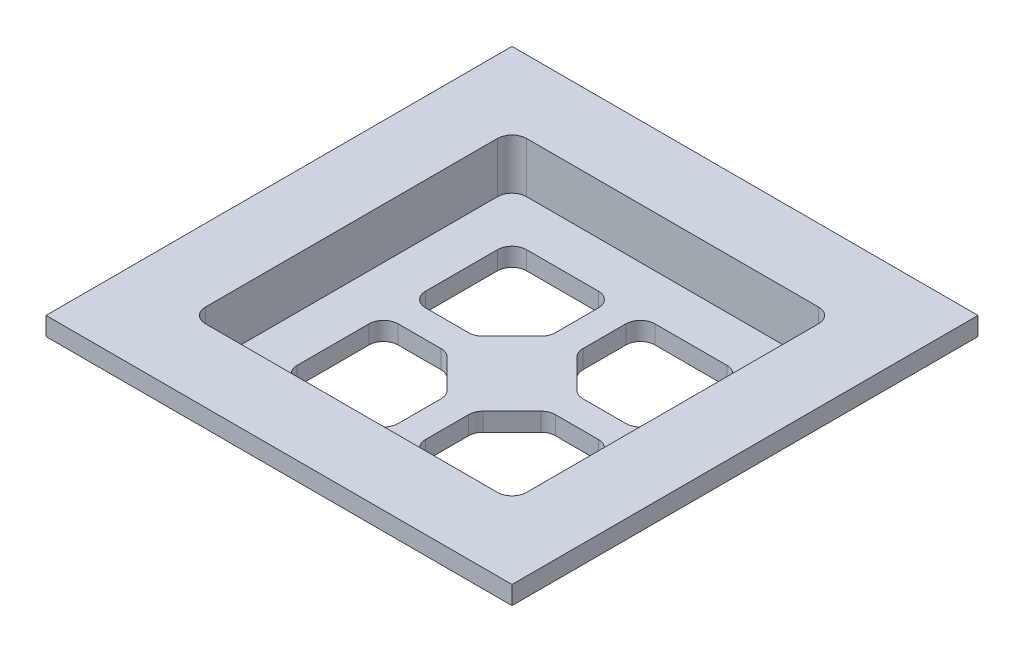
from build123d import *

# Parameters (mm, degrees)
SKETCH3_W           = 47.117
SKETCH3_H           = 47.117
BOSS_EXTRUDE1_DEPTH = 5.500799822
CUT_EXTRUDE2_REACH  = 7.501
SKETCH6_W           = 11
SKETCH6_H           = 11
SKETCH7_W           = 50.8
SKETCH7_H           = 50.8
SKETCH7_W_2         = 35
SKETCH7_H_2         = 35
BOSS_EXTRUDE2_DEPTH = 1.999999976
SKETCH12_W          = 35
SKETCH12_H          = 35
CUT_EXTRUDE3_DEPTH  = 3.499999912
BOSS_EXTRUDE4_DEPTH = 2.0008
FILLET3_R           = 1.5875
CUT_EXTRUDE5_DEPTH  = 5.5008


with BuildPart() as part:
    # Sketch3 → Boss-Extrude1 (new body)
    with BuildSketch(Plane(origin=(0, 0, 0), x_dir=(1, 0, 0), z_dir=(0, 1, 0))):
        with Locations((23.8125, 23.8125)):
            Rectangle(SKETCH3_W, SKETCH3_H)
    extrude(amount=BOSS_EXTRUDE1_DEPTH)

    # Sketch6 → Cut-Extrude2 (cut, up to next)
    with BuildSketch(Plane(origin=(0, 5.500799822, 0), x_dir=(1, 0, 0), z_dir=(0, 1, 0)), mode=Mode.PRIVATE) as cut_extrude2_sk1:
        with Locations((16.8125, 30.8125)):
            Rectangle(SKETCH6_W, SKETCH6_H)
    cut_extrude2_tool1 = extrude(cut_extrude2_sk1.sketch, amount=-CUT_EXTRUDE2_REACH, mode=Mode.PRIVATE) & part.part
    add(cut_extrude2_tool1.solids().sort_by_distance((16.8125, 5.5008, -30.8125))[0], mode=Mode.SUBTRACT)
    # Sketch6 → Cut-Extrude2 (cut, up to next)
    with BuildSketch(Plane(origin=(0, 5.500799822, 0), x_dir=(1, 0, 0), z_dir=(0, 1, 0)), mode=Mode.PRIVATE) as cut_extrude2_sk2:
        with Locations((30.8125, 30.8125)):
            Rectangle(SKETCH6_W, SKETCH6_H)
    cut_extrude2_tool2 = extrude(cut_extrude2_sk2.sketch, amount=-CUT_EXTRUDE2_REACH, mode=Mode.PRIVATE) & part.part
    add(cut_extrude2_tool2.solids().sort_by_distance((30.8125, 5.5008, -30.8125))[0], mode=Mode.SUBTRACT)
    # Sketch6 → Cut-Extrude2 (cut, up to next)
    with BuildSketch(Plane(origin=(0, 5.500799822, 0), x_dir=(1, 0, 0), z_dir=(0, 1, 0)), mode=Mode.PRIVATE) as cut_extrude2_sk3:
        with Locations((30.8125, 16.8125)):
            Rectangle(SKETCH6_W, SKETCH6_H)
    cut_extrude2_tool3 = extrude(cut_extrude2_sk3.sketch, amount=-CUT_EXTRUDE2_REACH, mode=Mode.PRIVATE) & part.part
    add(cut_extrude2_tool3.solids().sort_by_distance((30.8125, 5.5008, -16.8125))[0], mode=Mode.SUBTRACT)
    # Sketch6 → Cut-Extrude2 (cut, up to next)
    with BuildSketch(Plane(origin=(0, 5.500799822, 0), x_dir=(1, 0, 0), z_dir=(0, 1, 0)), mode=Mode.PRIVATE) as cut_extrude2_sk4:
        with Locations((16.8125, 16.8125)):
            Rectangle(SKETCH6_W, SKETCH6_H)
    cut_extrude2_tool4 = extrude(cut_extrude2_sk4.sketch, amount=-CUT_EXTRUDE2_REACH, mode=Mode.PRIVATE) & part.part
    add(cut_extrude2_tool4.solids().sort_by_distance((16.8125, 5.5008, -16.8125))[0], mode=Mode.SUBTRACT)

    # Sketch7 → Boss-Extrude2 (add)
    with BuildSketch(Plane(origin=(0, 5.500799822, 0), x_dir=(1, 0, 0), z_dir=(0, 1, 0))):
        with Locations((23.8125, 23.8125)):
            Rectangle(SKETCH7_W, SKETCH7_H)
        with Locations((23.8125, 23.8125)):
            Rectangle(SKETCH7_W_2, SKETCH7_H_2, mode=Mode.SUBTRACT)
    extrude(amount=BOSS_EXTRUDE2_DEPTH)

    # Sketch12 → Cut-Extrude3 (cut)
    with BuildSketch(Plane(origin=(0, 5.500799822, 0), x_dir=(1, 0, 0), z_dir=(0, 1, 0))):
        with Locations((23.8125, 23.8125)):
            Rectangle(SKETCH12_W, SKETCH12_H)
    extrude(amount=-CUT_EXTRUDE3_DEPTH, mode=Mode.SUBTRACT)

    # Sketch11 → Boss-Extrude4 (add)
    with BuildSketch(Plane(origin=(0, 2.00079991, 0), x_dir=(1, 0, 0), z_dir=(0, 1, 0))):
        Polygon((22.3125, 29.383567812), (25.3125, 29.383567812), (29.383567812, 25.3125), (29.383567812, 22.3125), (25.3125, 18.241432188), (22.3125, 18.241432188), (18.241432188, 22.3125), (18.241432188, 25.3125), align=None)
    extrude(amount=-BOSS_EXTRUDE4_DEPTH)

    # Fillet3
    fillet3_edges = [part.edges().sort_by_distance(p)[0] for p in [
        (29.383567812, 1.00039991, -22.3125),
        (25.3125, 1.00039991, -18.241432188),
        (22.3125, 1.00039991, -18.241432188),
        (18.241432188, 1.00039991, -22.3125),
        (18.241432188, 1.00039991, -25.3125),
        (22.3125, 1.00039991, -29.383567812),
        (25.3125, 1.00039991, -29.383567812),
        (29.383567812, 1.00039991, -25.3125),
        (36.3125, 1.000399955, -22.3125),
        (36.3125, 1.000399955, -11.3125),
        (25.3125, 1.000399955, -11.3125),
        (11.3125, 1.000399955, -36.3125),
        (22.3125, 1.000399955, -36.3125),
        (11.3125, 1.000399955, -25.3125),
        (22.3125, 1.000399955, -11.3125),
        (11.3125, 1.000399955, -11.3125),
        (11.3125, 1.000399955, -22.3125),
        (36.3125, 1.000399955, -25.3125),
        (25.3125, 1.000399955, -36.3125),
        (36.3125, 1.000399955, -36.3125),
        (6.3125, 4.750799854, -6.3125),
        (41.3125, 4.750799854, -6.3125),
        (41.3125, 4.750799854, -41.3125),
        (6.3125, 4.750799854, -41.3125),
        (0.254, 2.750399911, -47.371),
        (47.371, 2.750399911, -47.371),
        (47.371, 2.750399911, -0.254),
        (0.254, 2.750399911, -0.254),
    ]]
    fillet(fillet3_edges, radius=FILLET3_R)

    # Sketch13 → Cut-Extrude5 (cut)
    with BuildSketch(Plane.XZ):
        with BuildLine():
            Line((0.254, -1.8415), (0.254, -45.7835))
            ThreePointArc((0.254, -45.7835), (0.718967985, -46.906032015), (1.8415, -47.371))
            Line((1.8415, -47.371), (45.7835, -47.371))
            ThreePointArc((45.7835, -47.371), (46.906032015, -46.906032015), (47.371, -45.7835))
            Line((47.371, -45.7835), (47.371, -1.8415))
            ThreePointArc((47.371, -1.8415), (46.906032015, -0.718967985), (45.7835, -0.254))
            Line((45.7835, -0.254), (1.8415, -0.254))
            ThreePointArc((1.8415, -0.254), (0.718967985, -0.718967985), (0.254, -1.8415))
        make_face()
        with BuildLine():
            Line((4.018000092, -5.605500092), (4.018000092, -42.019499908))
            ThreePointArc((4.018000092, -42.019499908), (4.482968077, -43.142031923), (5.605500092, -43.606999908))
            Line((5.605500092, -43.606999908), (42.019499908, -43.606999908))
            ThreePointArc((42.019499908, -43.606999908), (43.142031923, -43.142031923), (43.606999908, -42.019499908))
            Line((43.606999908, -42.019499908), (43.606999908, -5.605500092))
            ThreePointArc((43.606999908, -5.605500092), (43.142031923, -4.482968077), (42.019499908, -4.018000092))
            Line((42.019499908, -4.018000092), (5.605500092, -4.018000092))
            ThreePointArc((5.605500092, -4.018000092), (4.482968077, -4.482968077), (4.018000092, -5.605500092))
        make_face(mode=Mode.SUBTRACT)
    extrude(amount=-CUT_EXTRUDE5_DEPTH, mode=Mode.SUBTRACT)


solid = part.part
